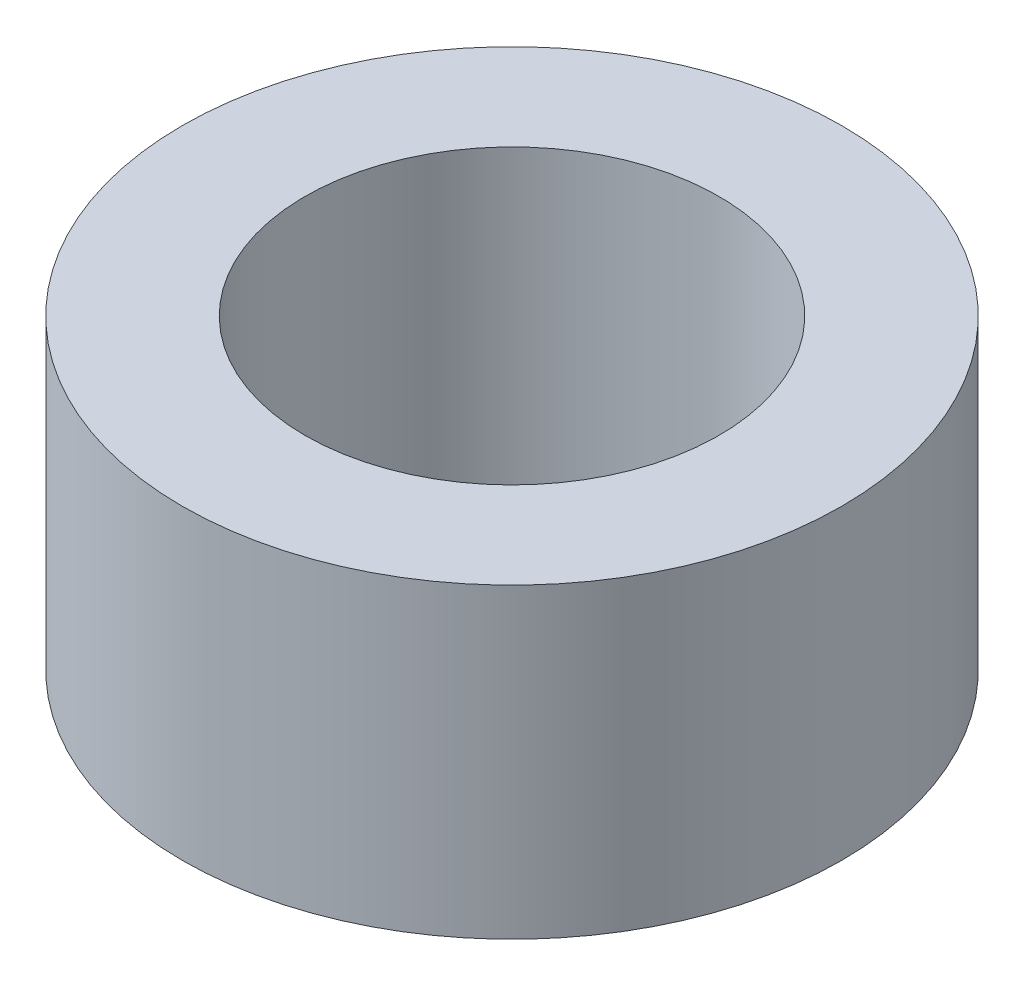
from build123d import *

# Parameters (mm, degrees)
SKETCH1_R           = 107.5
BOSS_EXTRUDE1_DEPTH = 100
SKETCH2_R           = 67.5
CUT_EXTRUDE1_DEPTH  = 100


with BuildPart() as part:
    # Sketch1 → Boss-Extrude1 (new body)
    with BuildSketch(Plane(origin=(0, 0, 0), x_dir=(1, 0, 0), z_dir=(0, 1, 0))):
        Circle(SKETCH1_R)
    extrude(amount=BOSS_EXTRUDE1_DEPTH)

    # Sketch2 → Cut-Extrude1 (cut)
    with BuildSketch(Plane(origin=(0, 100, 0), x_dir=(1, 0, 0), z_dir=(0, 1, 0))):
        Circle(SKETCH2_R)
    extrude(amount=-CUT_EXTRUDE1_DEPTH, mode=Mode.SUBTRACT)


solid = part.part
